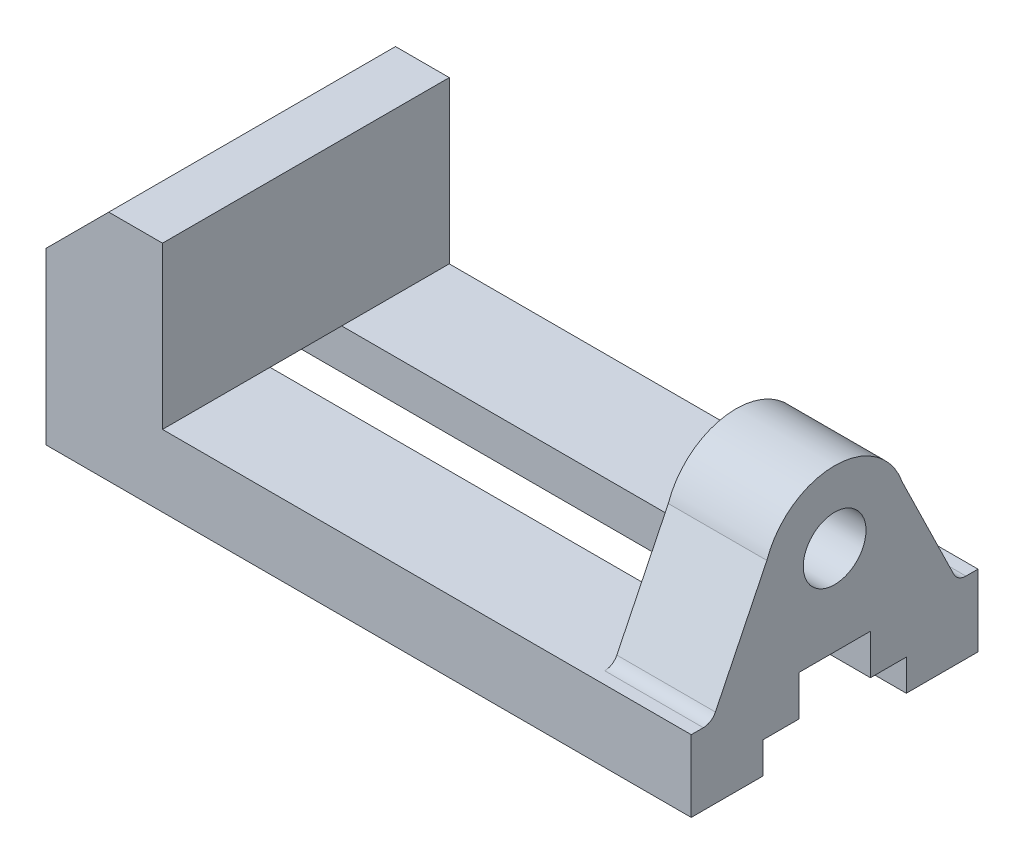
from build123d import *

# Parameters (mm, degrees)
IZIM1_W                     = 144
IZIM1_H                     = 64
Y_KSEKLIK_EKSTR_ZYON1_DEPTH = 16
KES_EKSTR_ZYON1_DEPTH       = 187
IZIM3_W                     = 22
IZIM3_H                     = 64
Y_KSEKLIK_EKSTR_ZYON2_DEPTH = 36
IZIM7_W                     = 26
IZIM7_H                     = 64
Y_KSEKLIK_EKSTR_ZYON3_DEPTH = 36
PAH2_SIZE                   = 14
KES_EKSTR_ZYON2_REACH       = 146
RADYUS1_R                   = 3
M16X2_0_DI_LI_DELIK1_D      = 14
M16X2_0_DI_LI_DELIK1_DEPTH  = 22
M6X1_0_DI_LI_DELIK1_D       = 5
M6X1_0_DI_LI_DELIK1_DEPTH   = 12
M6X1_0_DI_LI_DELIK1_TIP     = 1.502151548


with BuildPart() as part:
    # Çizim1 → Yükseklik-Ekstrüzyon1 (new body)
    with BuildSketch(Plane(origin=(0, 0, 0), x_dir=(1, 0, 0), z_dir=(0, 1, 0))):
        with Locations((-0.730223124, -0.055172414)):
            Rectangle(IZIM1_W, IZIM1_H)
    extrude(amount=Y_KSEKLIK_EKSTR_ZYON1_DEPTH)

    # Çizim2 → Kes-Ekstrüzyon1 (cut)
    with BuildSketch(Plane(origin=(71.269776876, 0, 0), x_dir=(0, 0, -1), z_dir=(1, 0, 0))):
        Polygon((-16.055172414, 0), (15.944827586, 0), (15.944827586, 7), (7.944827586, 7), (7.944827586, 16), (-8.055172414, 16), (-8.055172414, 7), (-16.055172414, 7), align=None)
    extrude(amount=-KES_EKSTR_ZYON1_DEPTH, mode=Mode.SUBTRACT)

    # Çizim3 → Yükseklik-Ekstrüzyon2 (add)
    with BuildSketch(Plane(origin=(0, 16, 0), x_dir=(1, 0, 0), z_dir=(0, 1, 0))):
        with Locations((60.269776876, -0.055172414)):
            Rectangle(IZIM3_W, IZIM3_H)
    extrude(amount=Y_KSEKLIK_EKSTR_ZYON2_DEPTH)

    # Çizim7 → Yükseklik-Ekstrüzyon3 (add)
    with BuildSketch(Plane(origin=(0, 16, 0), x_dir=(1, 0, 0), z_dir=(0, 1, 0))):
        with Locations((-59.730223124, -0.055172414)):
            Rectangle(IZIM7_W, IZIM7_H)
    extrude(amount=Y_KSEKLIK_EKSTR_ZYON3_DEPTH)

    # Pah2
    pah2_edges = [part.edges().sort_by_distance(p)[0] for p in [
        (-72.730223124, 52, 0.055172414),
    ]]
    chamfer(pah2_edges, length=PAH2_SIZE)

    # Çizim8 → Kes-Ekstrüzyon2 (cut, up to next)
    with BuildSketch(Plane(origin=(71.269776876, 0, 0), x_dir=(0, 0, -1), z_dir=(1, 0, 0)), mode=Mode.PRIVATE) as kes_ekstr_zyon2_sk1:
        with BuildLine():
            ThreePointArc((-15.175713521, 41.231561586), (-9.336740585, 49.03274692), (-0.055172468, 52))
            Line((-0.055172468, 52), (-32.055172414, 52))
            Line((-32.055172414, 52), (-32.055172414, 16))
            Line((-32.055172414, 16), (-27.481968367, 16))
            Line((-27.481968367, 16), (-15.175713521, 41.231561586))
        make_face()
    kes_ekstr_zyon2_tool1 = extrude(kes_ekstr_zyon2_sk1.sketch, amount=-KES_EKSTR_ZYON2_REACH, mode=Mode.PRIVATE) & part.part
    add(kes_ekstr_zyon2_tool1.solids().sort_by_distance((71.269777, 38.337323, 23.916372))[0], mode=Mode.SUBTRACT)
    # Çizim8 → Kes-Ekstrüzyon2 (cut, up to next)
    with BuildSketch(Plane(origin=(71.269776876, 0, 0), x_dir=(0, 0, -1), z_dir=(1, 0, 0)), mode=Mode.PRIVATE) as kes_ekstr_zyon2_sk2:
        with BuildLine():
            Line((15.065368693, 41.231561586), (27.371623539, 16))
            Line((27.371623539, 16), (31.944827586, 16))
            Line((31.944827586, 16), (31.944827586, 52))
            Line((31.944827586, 52), (-0.055172468, 52))
            ThreePointArc((-0.055172468, 52), (9.226395713, 49.032746952), (15.065368693, 41.231561586))
        make_face()
    kes_ekstr_zyon2_tool2 = extrude(kes_ekstr_zyon2_sk2.sketch, amount=-KES_EKSTR_ZYON2_REACH, mode=Mode.PRIVATE) & part.part
    add(kes_ekstr_zyon2_tool2.solids().sort_by_distance((71.269777, 38.337323, -23.806027))[0], mode=Mode.SUBTRACT)

    # Radyus1
    radyus1_edges = [part.edges().sort_by_distance(p)[0] for p in [
        (60.269776876, 16, 27.481968367),
        (60.269776876, 16, -27.371623539),
    ]]
    fillet(radyus1_edges, radius=RADYUS1_R)

    # M16x2.0 Dişli Delik1
    with Locations(Plane(origin=(71.269776876, 36, 0.055172414), x_dir=(0, 0, 1), z_dir=(1, 0, 0))):
        with Locations((0, 0)):
            Hole(M16X2_0_DI_LI_DELIK1_D / 2, depth=M16X2_0_DI_LI_DELIK1_DEPTH)

    # M6x1.0 Dişli Delik1
    with Locations(Plane(origin=(-36.730223124, 0, -23.086256015), x_dir=(0, 0, -1), z_dir=(0, -1, 0))):
        with Locations((0, 0), (-45.141428429, 0), (-45.141428429, 72), (-1.141428429, 72)):
            Hole(M6X1_0_DI_LI_DELIK1_D / 2, depth=M6X1_0_DI_LI_DELIK1_DEPTH)
            with Locations((0, 0, -(M6X1_0_DI_LI_DELIK1_DEPTH + M6X1_0_DI_LI_DELIK1_TIP / 2))):  # 118° drill point
                Cone(0, M6X1_0_DI_LI_DELIK1_D / 2, M6X1_0_DI_LI_DELIK1_TIP, mode=Mode.SUBTRACT)


solid = part.part
